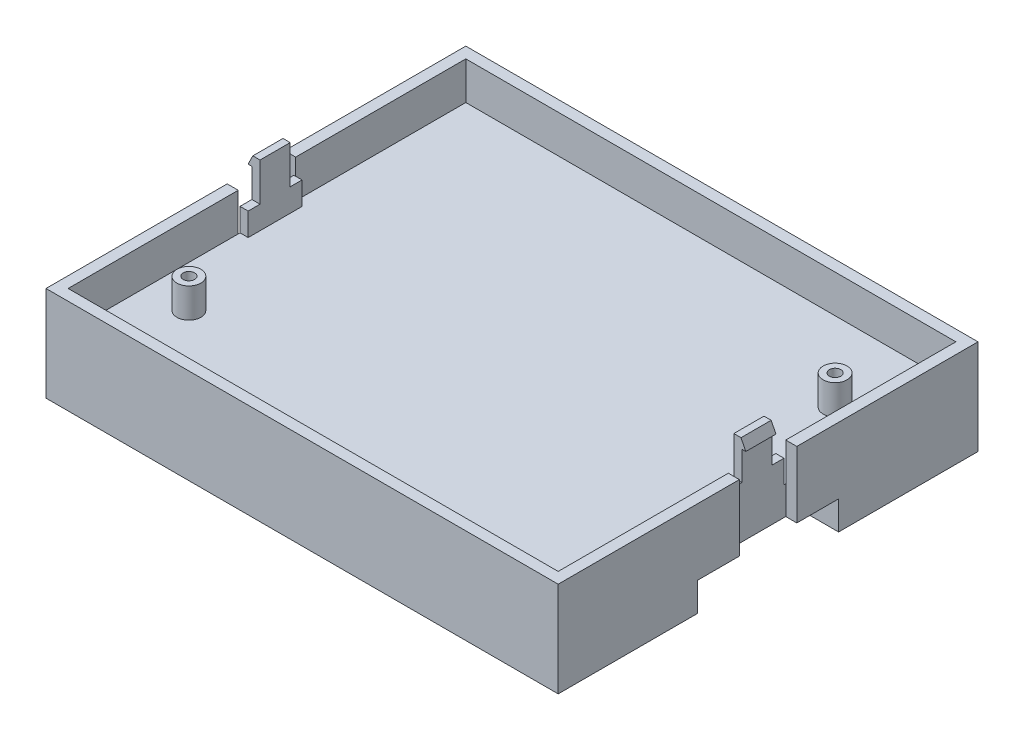
from build123d import *

# Parameters (mm, degrees)
SKETCH1_W           = 107
SKETCH1_H           = 87.7
BOSS_EXTRUDE1_DEPTH = 13.85
SKETCH2_W           = 102.38
SKETCH2_H           = 83.08
CUT_EXTRUDE1_DEPTH  = 7.9
SKETCH4_R           = 2.5
SKETCH4_R_2         = 1.2
BOSS_EXTRUDE2_DEPTH = 6.2
SKETCH7_W           = 11.25
SKETCH7_H           = 4.8
BOSS_EXTRUDE3_DEPTH = 1.7
BOSS_EXTRUDE4_DEPTH = 3.15
CUT_EXTRUDE8_START  = -12
CUT_EXTRUDE8_DEPTH  = 20
BOSS_EXTRUDE7_DEPTH = 6
SKETCH24_W          = 8.731680323
SKETCH24_H          = 3
CUT_EXTRUDE10_DEPTH = 91.556729163
CHAMFER1_SIZE       = 1.5
CHAMFER2_SIZE       = 1.5


with BuildPart() as part:
    # Sketch1 → Boss-Extrude1 (new body)
    with BuildSketch(Plane(origin=(0, 0, 0), x_dir=(1, 0, 0), z_dir=(0, 1, 0))):
        Rectangle(SKETCH1_W, SKETCH1_H)
    extrude(amount=BOSS_EXTRUDE1_DEPTH)

    # Sketch2 → Cut-Extrude1 (cut)
    with BuildSketch(Plane(origin=(0, 13.85, 0), x_dir=(1, 0, 0), z_dir=(0, 1, 0))):
        Rectangle(SKETCH2_W, SKETCH2_H)
    extrude(amount=-CUT_EXTRUDE1_DEPTH, mode=Mode.SUBTRACT)

    # Sketch4 → Boss-Extrude2 (add)
    with BuildSketch(Plane(origin=(0, 5.95, 0), x_dir=(1, 0, 0), z_dir=(0, 1, 0))):
        with Locations((-42.5, -25)):
            Circle(SKETCH4_R)
        with Locations((-42.5, -25)):
            Circle(SKETCH4_R_2, mode=Mode.SUBTRACT)
        with Locations((42.5, 25)):
            Circle(SKETCH4_R)
        with Locations((42.5, 25)):
            Circle(SKETCH4_R_2, mode=Mode.SUBTRACT)
    extrude(amount=BOSS_EXTRUDE2_DEPTH)

    # Sketch7 → Boss-Extrude3 (add)
    with BuildSketch(Plane(origin=(-51.19, 0, 0), x_dir=(0, 0, -1), z_dir=(1, 0, 0))):
        with Locations((0, 8.35)):
            Rectangle(SKETCH7_W, SKETCH7_H)
    boss_extrude3 = extrude(amount=BOSS_EXTRUDE3_DEPTH)

    # Sketch8 → Boss-Extrude4 (add, symmetric)
    with BuildSketch(Plane.XY):
        Polygon((-49.49, 10.75), (-49.49, 18.75), (-50.99, 18.75), (-51.99, 16.75), (-51.19, 16.75), (-51.19, 10.75), align=None)
    boss_extrude4 = extrude(amount=BOSS_EXTRUDE4_DEPTH, both=True)

    # Mirror1: Boss-Extrude4 across plane
    add(boss_extrude4.mirror(Plane(origin=(0, 0, 0), x_dir=(0, 0, 1), z_dir=(1, 0, 0))))

    # Mirror2: Boss-Extrude3 across plane
    add(boss_extrude3.mirror(Plane(origin=(0, 0, 0), x_dir=(0, 0, 1), z_dir=(1, 0, 0))))

    # Sketch22 → Cut-Extrude8 (cut)
    with BuildSketch(Plane(origin=(0, 5.95, 0), x_dir=(1, 0, 0), z_dir=(0, 1, 0)).offset(CUT_EXTRUDE8_START)):
        Polygon((-51.19, 0), (-51.19, -6), (-53.5, -6), (-53.5, 6), (-51.19, 6), align=None)
    cut_extrude8 = extrude(amount=CUT_EXTRUDE8_DEPTH, mode=Mode.SUBTRACT)

    # Mirror3: Cut-Extrude8 across plane
    add(cut_extrude8.mirror(Plane(origin=(0, 0, 0), x_dir=(0, 0, 1), z_dir=(1, 0, 0))), mode=Mode.SUBTRACT)

    # Sketch23 → Boss-Extrude7 (add)
    with BuildSketch(Plane(origin=(0, 0, 0), x_dir=(-1, 0, 0), z_dir=(0, -1, 0))):
        Polygon((53.5, -43.85), (-53.5, -43.85), (-53.5, -14.731680323), (-37.056729163, -14.731680323), (-37.056729163, -6), (37.056729163, -6), (37.056729163, -14.731680323), (53.5, -14.731680323), align=None)
    boss_extrude7 = extrude(amount=BOSS_EXTRUDE7_DEPTH)

    # Sketch24 → Cut-Extrude10 (cut, through all)
    with BuildSketch(Plane(origin=(37.056729163, 0, 0), x_dir=(0, 0, -1), z_dir=(1, 0, 0))):
        with Locations((-10.365840161, -1.5)):
            Rectangle(SKETCH24_W, SKETCH24_H)
    cut_extrude10 = extrude(amount=-CUT_EXTRUDE10_DEPTH, mode=Mode.SUBTRACT)

    # Chamfer1
    chamfer1_edges = [part.edges().sort_by_distance(p)[0] for p in [
        (0, -3, 6),
    ]]
    chamfer(chamfer1_edges, length=CHAMFER1_SIZE)

    # Mirror4: Boss-Extrude7 across plane
    add(boss_extrude7.mirror(Plane.XY))

    # Mirror7: Cut-Extrude10 across plane
    add(cut_extrude10.mirror(Plane.XY), mode=Mode.SUBTRACT)

    # Chamfer2
    chamfer2_edges = [part.edges().sort_by_distance(p)[0] for p in [
        (0, -3, -6),
    ]]
    chamfer(chamfer2_edges, length=CHAMFER2_SIZE)


solid = part.part
